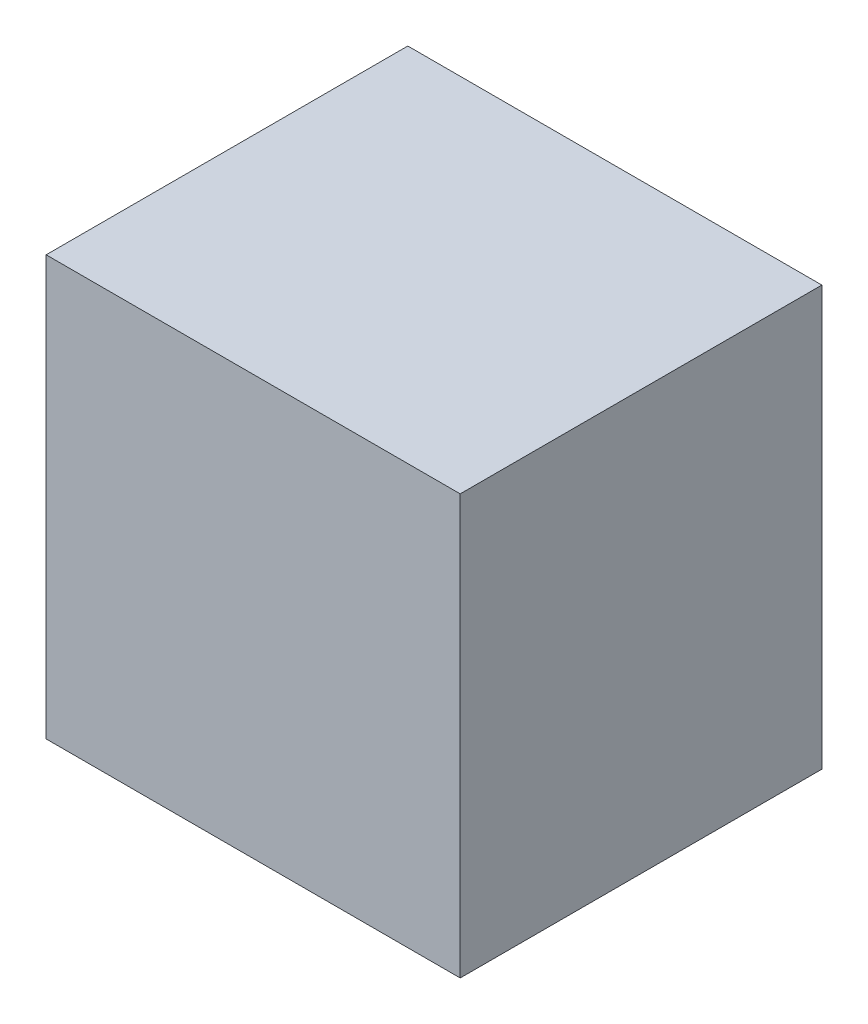
from build123d import *

# Parameters (mm, degrees)
SKETCH1_W           = 7.9
SKETCH1_H           = 6.9
BOSS_EXTRUDE1_DEPTH = 8


with BuildPart() as part:
    # Sketch1 → Boss-Extrude1 (new body)
    with BuildSketch(Plane(origin=(0, 0, 0), x_dir=(1, 0, 0), z_dir=(0, 1, 0))):
        Rectangle(SKETCH1_W, SKETCH1_H)
    extrude(amount=BOSS_EXTRUDE1_DEPTH)


solid = part.part
